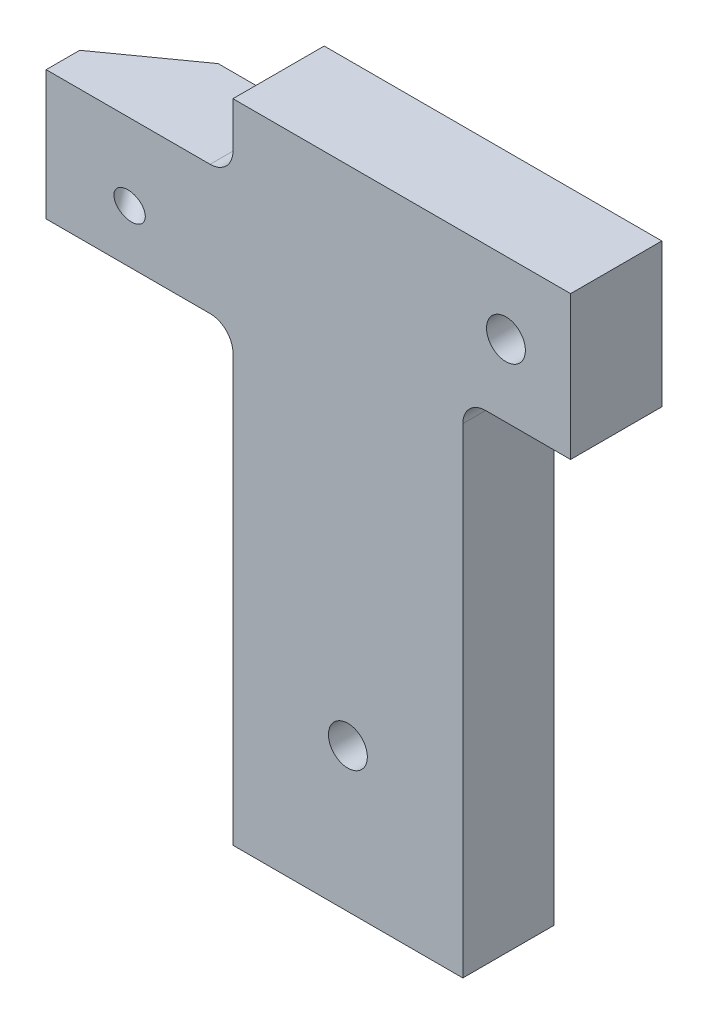
from build123d import *

# Parameters (mm, degrees)
SKETCH1_W                                      = 36.5
SKETCH1_H                                      = 45
BOSS_EXTRUDE1_DEPTH                            = 6.35
SKETCH4_W                                      = 50
SKETCH4_H                                      = 50
CUT_EXTRUDE1_DEPTH                             = 4
CUT_EXTRUDE2_DEPTH                             = 19
F_2_56_TAPPED_HOLE1_D                          = 1.778
CBORE_FOR_2_SOCKET_HEAD_CAP_SCREW1_D           = 2.7051
CBORE_FOR_2_SOCKET_HEAD_CAP_SCREW1_CBORE_D     = 4.7625
CBORE_FOR_2_SOCKET_HEAD_CAP_SCREW1_CBORE_DEPTH = 2.18439746


with BuildPart() as part:
    # Sketch1 → Boss-Extrude1 (new body)
    with BuildSketch(Plane.XY):
        with Locations((18.25, 22.5)):
            Rectangle(SKETCH1_W, SKETCH1_H)
    extrude(amount=BOSS_EXTRUDE1_DEPTH)

    # Sketch4 → Cut-Extrude1 (cut)
    with BuildSketch(Plane(origin=(-4.216220414, 1.201768304, -5.904135163), x_dir=(-0.816779309, -0.191151006, 0.544364633), z_dir=(-0.573332653, 0.16341959, -0.802859705))):
        with Locations((-8.601795261, 43.553754656)):
            Rectangle(SKETCH4_W, SKETCH4_H)
    extrude(amount=-CUT_EXTRUDE1_DEPTH, mode=Mode.SUBTRACT)

    # Sketch7 → Cut-Extrude2 (cut)
    with BuildSketch(Plane(origin=(0, 0, 0), x_dir=(-1, 0, 0), z_dir=(0, 0, -1))):
        with BuildLine():
            Line((0, 0), (-13, 0))
            Line((-13, 0), (-13, 29.6625))
            ThreePointArc((-13, 29.6625), (-12.535032015, 30.785032015), (-11.4125, 31.25))
            Line((-11.4125, 31.25), (0, 31.25))
            Line((0, 31.25), (0, 0))
        make_face()
        with BuildLine():
            Line((-36.5, 0), (-29, 0))
            Line((-29, 0), (-29, 33.4125))
            ThreePointArc((-29, 33.4125), (-29.464967985, 34.535032015), (-30.5875, 35))
            Line((-30.5875, 35), (-36.5, 35))
            Line((-36.5, 35), (-36.5, 0))
        make_face()
        with BuildLine():
            Line((-13, 45), (-13, 41.8375))
            ThreePointArc((-13, 41.8375), (-12.535032015, 40.714967985), (-11.4125, 40.25))
            Line((-11.4125, 40.25), (0, 40.25))
            Line((0, 40.25), (0, 45))
            Line((0, 45), (-13, 45))
        make_face()
    extrude(amount=-CUT_EXTRUDE2_DEPTH, mode=Mode.SUBTRACT)

    # #2-56 Tapped Hole1 (through all)
    with Locations(Plane(origin=(-1.9228898, 0.548089945, -2.692696342), x_dir=(-0.816779309, -0.191151006, 0.544364633), z_dir=(-0.573332653, 0.16341959, -0.802859705))):
        with Locations((-7.966944936, 34.99181106)):
            Hole(F_2_56_TAPPED_HOLE1_D / 2)

    # CBORE for #2 Socket Head Cap Screw1 (through all)
    with Locations(Plane(origin=(0, 0, 0), x_dir=(-1, 0, 0), z_dir=(0, 0, -1))):
        with Locations((-21, 10), (-32, 40)):
            CounterBoreHole(CBORE_FOR_2_SOCKET_HEAD_CAP_SCREW1_D / 2, CBORE_FOR_2_SOCKET_HEAD_CAP_SCREW1_CBORE_D / 2, CBORE_FOR_2_SOCKET_HEAD_CAP_SCREW1_CBORE_DEPTH)


solid = part.part
